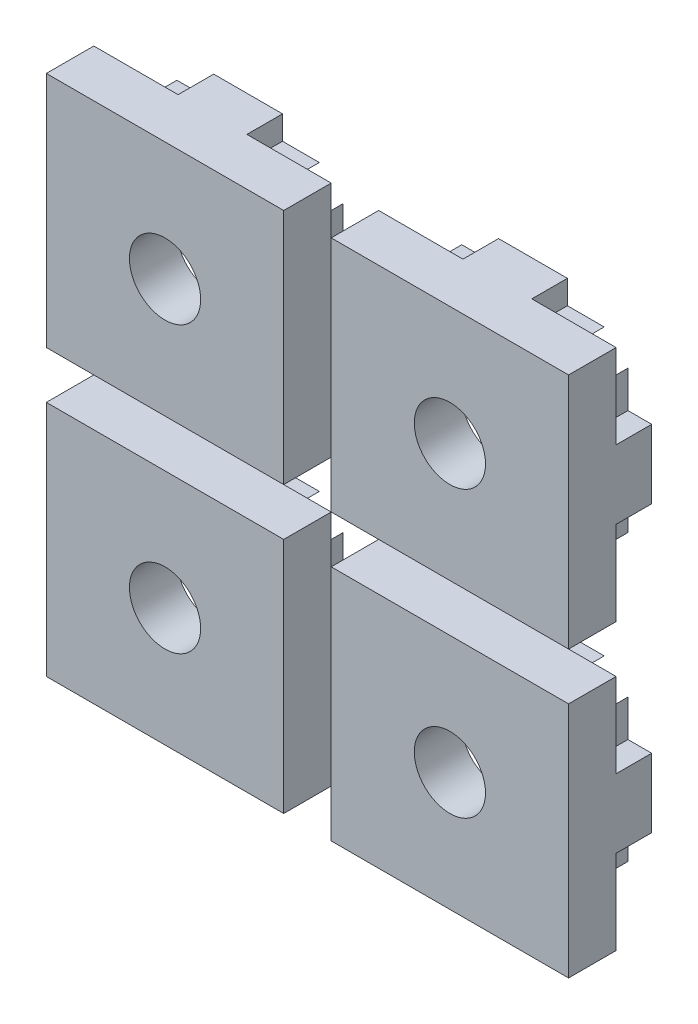
from build123d import *

# Parameters (mm, degrees)
SKETCH1_W                = 10
SKETCH1_H                = 10
SKETCH1_R                = 1.5
MAIN_DEPTH               = 2
ANTIROTATIONSYSTEM_DEPTH = 1.5
CIRPATTERN1_COUNT        = 4
LPATTERN1_COUNT          = 2
LPATTERN1_PITCH          = 12
LPATTERN2_COUNT          = 2
LPATTERN2_PITCH          = 12


with BuildPart() as part:
    # Sketch1 → Main (new body)
    with BuildSketch(Plane.XY):
        Rectangle(SKETCH1_W, SKETCH1_H)
        Circle(SKETCH1_R, mode=Mode.SUBTRACT)
    extrude(amount=MAIN_DEPTH)

    # Sketch2 → AntiRotationSystem (add)
    with BuildSketch(Plane(origin=(0, 0, 0), x_dir=(-1, 0, 0), z_dir=(0, 0, -1))):
        Polygon((-5, 1.45), (-4, 1.45), (-4, 3), (-2, 1), (-2, -1), (-4, -3), (-4, -1.45), (-5, -1.45), align=None)
    antirotationsystem = extrude(amount=ANTIROTATIONSYSTEM_DEPTH)

    # CirPattern1: AntiRotationSystem ×4 about axis
    cirpattern1_axis = Axis((0, 0, 0), (0, 0, 1))
    for i in range(1, CIRPATTERN1_COUNT):
        add(antirotationsystem.rotate(cirpattern1_axis, i * 360 / CIRPATTERN1_COUNT))


with BuildPart() as lpattern1_1:
    # LPattern1: pattern copy
    add(part.part.moved(Location(Vector(0, -1, 0) * (1 * LPATTERN1_PITCH))))


with BuildPart() as lpattern2_1:
    # LPattern2: pattern copy
    add(part.part.moved(Location(Vector(-1, 0, 0) * (1 * LPATTERN2_PITCH))))


with BuildPart() as lpattern2_2:
    # LPattern2: pattern copy
    add(lpattern1_1.part.moved(Location(Vector(-1, 0, 0) * (1 * LPATTERN2_PITCH))))


solid = Compound([part.part, lpattern1_1.part, lpattern2_1.part, lpattern2_2.part])
